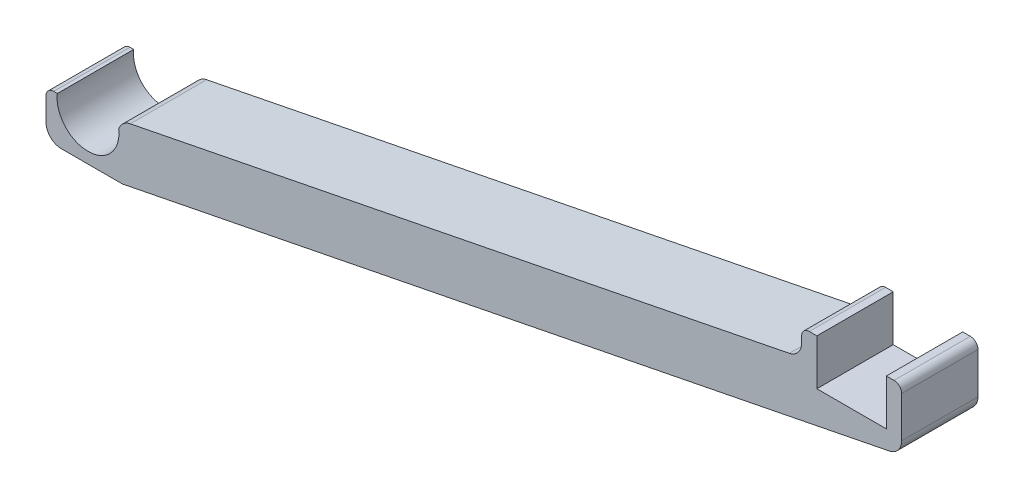
from build123d import *

# Parameters (mm, degrees)
EXTRUDE_1_DEPTH = 10
FILLET_1_R      = 2
FILLET_2_R      = 1


with BuildPart() as part:
    # Эскиз1 → Бобышка-Вытянуть1 (new body)
    with BuildSketch(Plane.XY):
        with BuildLine():
            Line((95.45, 22.75), (95.45, 16.75))
            Line((95.45, 16.75), (104.55, 16.75))
            Line((104.55, 16.75), (104.55, 22.75))
            Line((104.55, 22.75), (106.55, 22.75))
            Line((106.55, 22.75), (106.55, 14.75))
            Line((106.55, 14.75), (4.5, -5.5))
            Line((4.5, -5.5), (-5.5, -5.5))
            Line((-5.5, -5.5), (-5.5, 0.5))
            Line((-5.5, 0.5), (-4.019017293, 0.5))
            ThreePointArc((-4.019017293, 0.5), (0, -4.05), (4.019017293, 0.5))
            Line((4.019017293, 0.5), (4.493506463, 1.63519453))
            Line((4.493506463, 1.63519453), (93.45, 19.287022008))
            Line((93.45, 19.287022008), (93.45, 22.75))
            Line((93.45, 22.75), (95.45, 22.75))
        make_face()
    extrude(amount=EXTRUDE_1_DEPTH)

    # Скругление1
    fillet_1_edges = [part.edges().sort_by_distance(p)[0] for p in [
        (4.493506463, 1.63519453, 5),
        (93.45, 19.287022008, 5),
        (106.55, 14.75, 5),
        (4.5, -5.5, 5),
        (-5.5, -5.5, 5),
    ]]
    fillet(fillet_1_edges, radius=FILLET_1_R)

    # Скругление2
    fillet_2_edges = [part.edges().sort_by_distance(p)[0] for p in [
        (93.45, 22.75, 5),
        (106.55, 22.75, 5),
        (-5.5, 0.5, 5),
    ]]
    fillet(fillet_2_edges, radius=FILLET_2_R)


solid = part.part
